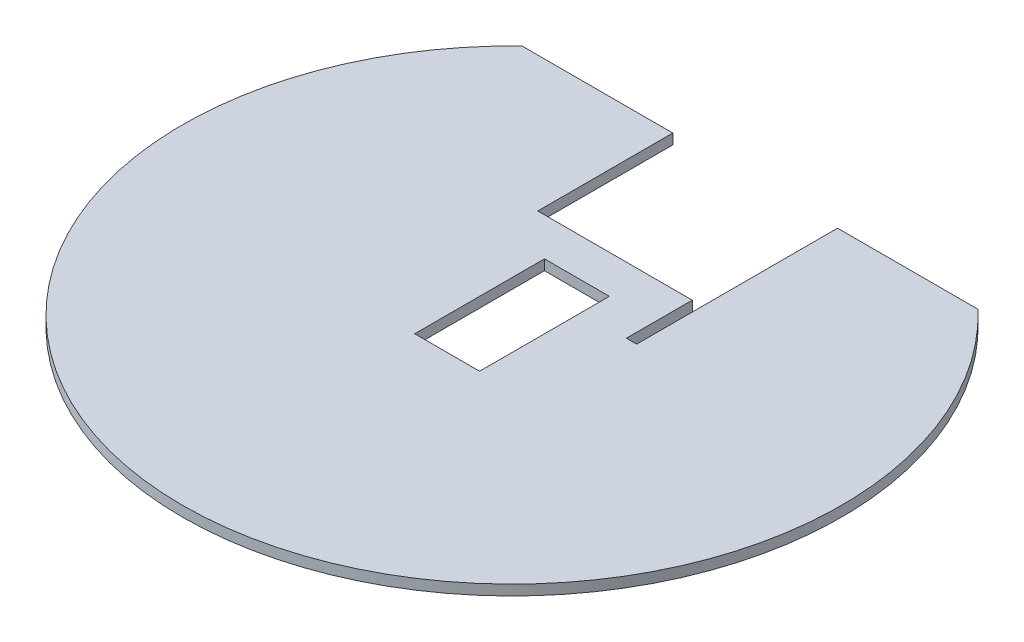
from build123d import *

# Parameters (mm, degrees)
BOSS_EXTRUDE1_DEPTH = 3.175
SKETCH2_W           = 20
SKETCH2_H           = 40
SKETCH2_W_2         = 3.175
SKETCH2_H_2         = 90.17
CUT_EXTRUDE1_DEPTH  = 4.175
SKETCH3_W           = 140.56164808
SKETCH3_H           = 25.4
CUT_EXTRUDE2_DEPTH  = 4.175


with BuildPart() as part:
    # Sketch1 → Boss-Extrude1 (new body)
    with BuildSketch(Plane(origin=(0, 0, 0), x_dir=(1, 0, 0), z_dir=(0, 1, 0))):
        with BuildLine():
            Line((23.8125, 31.75), (-23.8125, 31.75))
            Line((-23.8125, 31.75), (-23.8125, 98.770060462))
            ThreePointArc((-23.8125, 98.770060462), (-62.861792847, -79.818262321), (101.6, 0))
            ThreePointArc((101.6, 0), (79.818262321, 62.861792847), (23.8125, 98.770060462))
            Line((23.8125, 98.770060462), (23.8125, 31.75))
        make_face()
    extrude(amount=BOSS_EXTRUDE1_DEPTH)

    # Sketch2 → Cut-Extrude1 (cut, through all)
    with BuildSketch(Plane(origin=(0, 3.175, 0), x_dir=(1, 0, 0), z_dir=(0, 1, 0))):
        Rectangle(SKETCH2_W, SKETCH2_H)
        with Locations((25.4, 56.515)):
            Rectangle(SKETCH2_W_2, SKETCH2_H_2)
    extrude(amount=-CUT_EXTRUDE1_DEPTH, mode=Mode.SUBTRACT)

    # Sketch3 → Cut-Extrude2 (cut, through all)
    with BuildSketch(Plane(origin=(0, 3.175, 0), x_dir=(1, 0, 0), z_dir=(0, 1, 0))):
        with Locations((0, 86.070060462)):
            Rectangle(SKETCH3_W, SKETCH3_H)
    extrude(amount=-CUT_EXTRUDE2_DEPTH, mode=Mode.SUBTRACT)


solid = part.part
